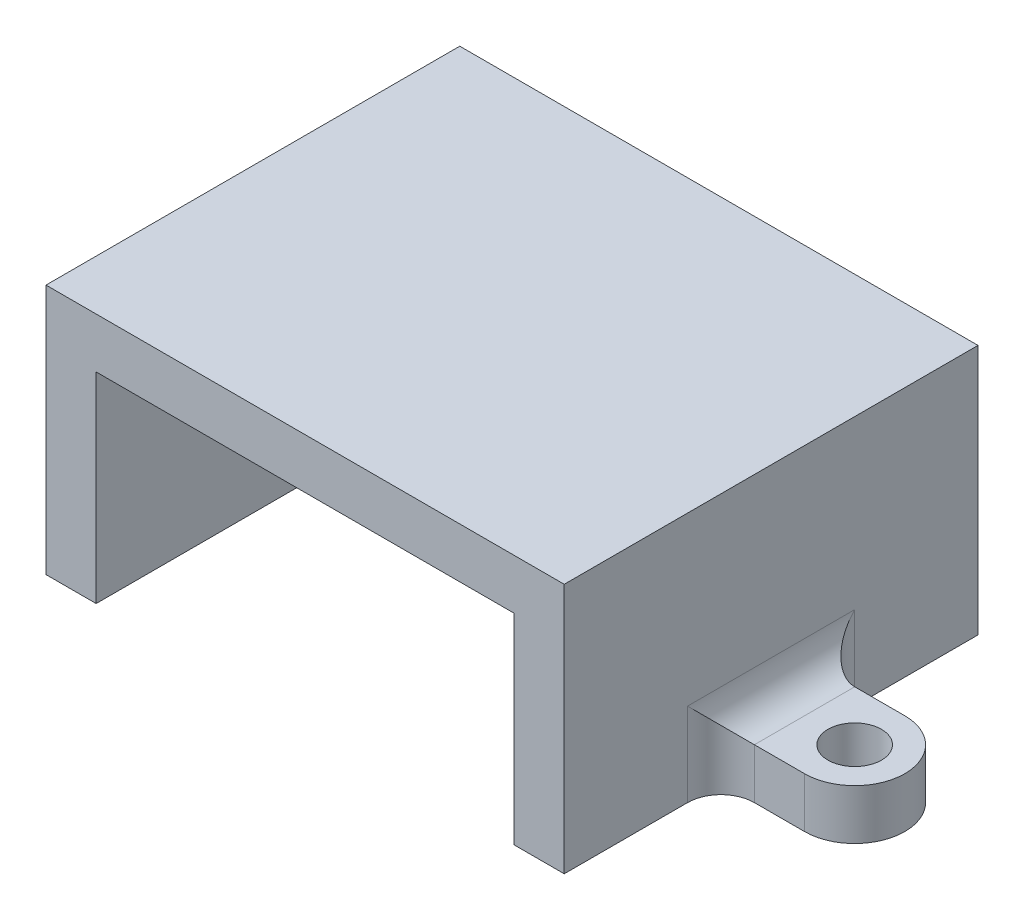
from build123d import *

# Parameters (mm, degrees)
EXTRUDE_1_DEPTH = 24.75
SKETCH_2_R      = 1.6
EXTRUDE_2_DEPTH = 3
FILLET_1_R      = 2


with BuildPart() as part:
    # 草图1 → 凸台-拉伸1 (new body)
    with BuildSketch(Plane.XY):
        Polygon((0, 0), (3, 0), (3, 12), (28, 12), (28, 0), (31, 0), (31, 15), (0, 15), align=None)
    extrude(amount=EXTRUDE_1_DEPTH)

    # 草图2 → 凸台-拉伸2 (add)
    with BuildSketch(Plane.XZ):
        with BuildLine():
            Line((36, 9.375), (31, 9.375))
            Line((31, 9.375), (31, 15.375))
            Line((31, 15.375), (36, 15.375))
            ThreePointArc((36, 15.375), (39, 12.375), (36, 9.375))
        make_face()
        with Locations((36, 12.375)):
            Circle(SKETCH_2_R, mode=Mode.SUBTRACT)
        with BuildLine():
            Line((0, 15.375), (0, 9.375))
            Line((0, 9.375), (-5, 9.375))
            ThreePointArc((-5, 9.375), (-8, 12.375), (-5, 15.375))
            Line((-5, 15.375), (0, 15.375))
        make_face()
        with Locations((-5, 12.375)):
            Circle(SKETCH_2_R, mode=Mode.SUBTRACT)
    extrude(amount=-EXTRUDE_2_DEPTH)

    # 圆角1
    fillet_1_edges = [part.edges().sort_by_distance(p)[0] for p in [
        (0, 3, 12.375),
        (0, 1.5, 15.375),
        (0, 1.5, 9.375),
        (31, 3, 12.375),
        (31, 1.5, 9.375),
        (31, 1.5, 15.375),
    ]]
    fillet(fillet_1_edges, radius=FILLET_1_R)


solid = part.part
